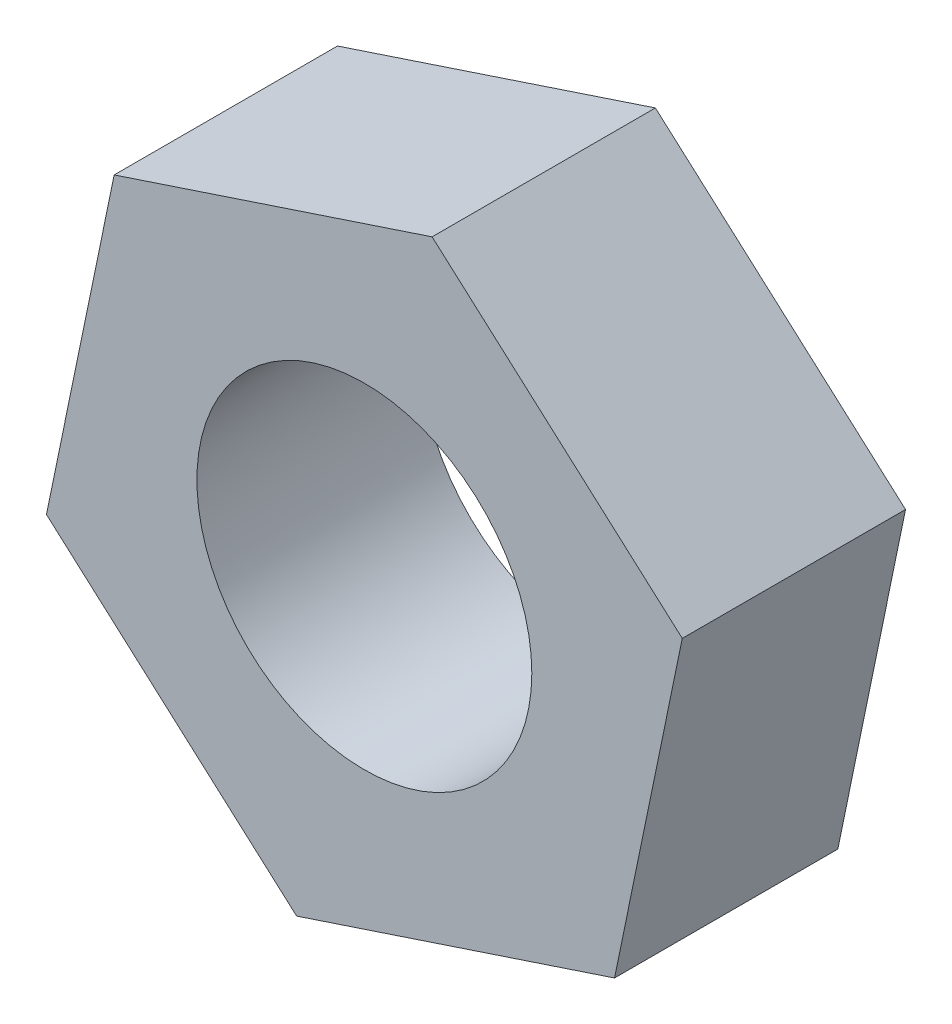
from build123d import *

# Parameters (mm, degrees)
SKETCH1_R      = 1.5
EXTRUDE2_DEPTH = 2


with BuildPart() as part:
    # Sketch1 → Extrude2 (new body)
    with BuildSketch(Plane.XY):
        Polygon((-0.606830241, -2.937985204), (2.240954702, -1.994523006), (2.847784943, 0.943462198), (0.606830241, 2.937985204), (-2.240954702, 1.994523006), (-2.847784943, -0.943462198), align=None)
        Circle(SKETCH1_R, mode=Mode.SUBTRACT)
    extrude(amount=EXTRUDE2_DEPTH)


solid = part.part
